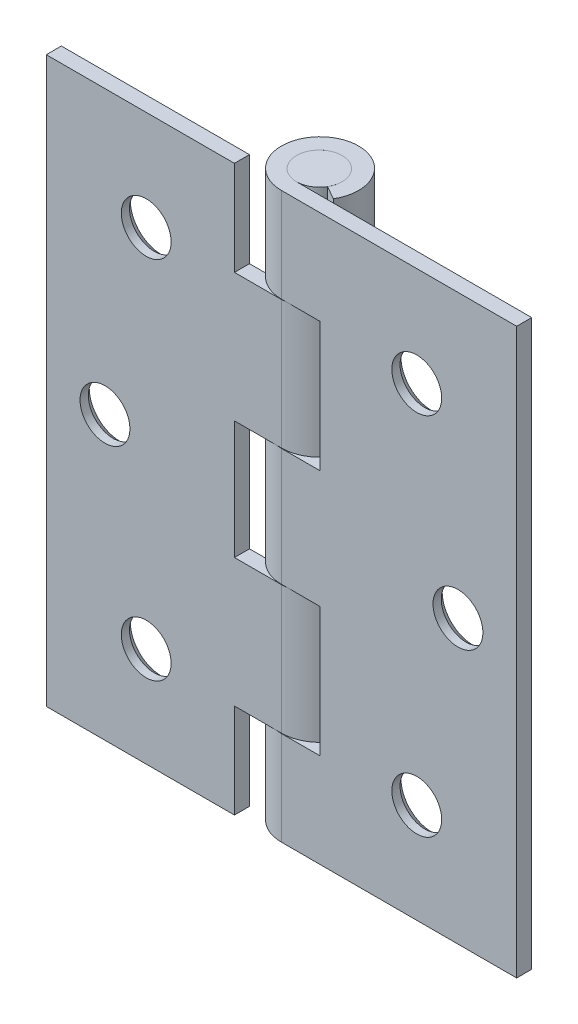
from build123d import *

# Parameters (mm, degrees)
EXTRUDE1_DEPTH                                = 38.1
CUT_EXTRUDE1_DEPTH                            = 9.382
CUT_EXTRUDE1_DEPTH_BACK                       = 3.032
EXTRUDE2_DEPTH                                = 8.68045
EXTRUDE2_DEPTH_BACK                           = 8.68045
EXTRUDE3_DEPTH                                = 8.68045
EXTRUDE3_DEPTH_BACK                           = 8.68045
EXTRUDE4_START                                = -21.43125
SKETCH5_W                                     = 25.4
SKETCH5_H                                     = 2.032
EXTRUDE4_DEPTH                                = 76.2
SKETCH6_W                                     = 3.0734
SKETCH6_H                                     = 76.2
CSK_FOR_8_FLAT_HEAD_MACHINE_SCREW2_AT_2_COUNT = 2
CSK_FOR_8_FLAT_HEAD_MACHINE_SCREW2_AT_2_PITCH = 25.258138545
CSK_FOR_8_FLAT_HEAD_MACHINE_SCREW2_AT_3_COUNT = 2
CSK_FOR_8_FLAT_HEAD_MACHINE_SCREW2_AT_3_PITCH = 25.258138545
CSK_FOR_8_FLAT_HEAD_MACHINE_SCREW2_AT_4_COUNT = 2
CSK_FOR_8_FLAT_HEAD_MACHINE_SCREW2_AT_4_PITCH = 48.768985563
CSK_FOR_8_FLAT_HEAD_MACHINE_SCREW2_AT_5_COUNT = 2
CSK_FOR_8_FLAT_HEAD_MACHINE_SCREW2_AT_5_PITCH = 47.6504
CSK_FOR_8_FLAT_HEAD_MACHINE_SCREW2_AT_6_COUNT = 2
CSK_FOR_8_FLAT_HEAD_MACHINE_SCREW2_AT_6_PITCH = 48.768985563


with BuildPart() as part:
    # Sketch1 → Extrude1 (new body, symmetric)
    with BuildSketch(Plane(origin=(0, 0, 0), x_dir=(1, 0, 0), z_dir=(0, 1, 0))):
        with BuildLine():
            Line((0, -3.0734), (31.75, -3.0734))
            Line((31.75, -3.0734), (31.75, -5.1054))
            Line((31.75, -5.1054), (0, -5.1054))
            ThreePointArc((0, -5.1054), (-2.565305705, 4.63283114), (4.464756325, -2.577728266))
            Line((4.464756325, -2.577728266), (2.661642476, -1.5367))
            ThreePointArc((2.661642476, -1.5367), (-1.5367, 2.661642476), (0, -3.0734))
        make_face()
    extrude(amount=EXTRUDE1_DEPTH, both=True)

    # Sketch2 → Cut-Extrude1 (cut, two sides)
    with BuildSketch(Plane(origin=(0, 0, 3.0734), x_dir=(-1, 0, 0), z_dir=(0, 0, -1))) as cut_extrude1_sk:
        Polygon((5.207, 217.478391172), (5.207, 38.1), (5.207, 25.4), (-5.207, 25.4), (-5.207, 7.9375), (5.207, 7.9375), (5.207, -7.9375), (-5.207, -7.9375), (-5.207, -25.4), (5.207, -25.4), (5.207, -38.1), (5.207, -217.478391172), (363.963782344, -217.478391172), (363.963782344, 217.478391172), align=None)
    extrude(amount=CUT_EXTRUDE1_DEPTH, mode=Mode.SUBTRACT)
    extrude(cut_extrude1_sk.sketch, amount=-CUT_EXTRUDE1_DEPTH_BACK, mode=Mode.SUBTRACT)


with BuildPart() as body_2:
    # Sketch3 → Extrude2 (new body, two sides)
    with BuildSketch(Plane(origin=(0, 16.66875, 0), x_dir=(-1, 0, 0), z_dir=(0, 1, 0))) as extrude2_sk:
        with BuildLine():
            Line((31.75, 5.1054), (31.75, 3.0734))
            Line((31.75, 3.0734), (0, 3.0734))
            ThreePointArc((0, 3.0734), (-1.5367, -2.661642476), (2.661642476, 1.5367))
            Line((2.661642476, 1.5367), (4.434312541, 2.627817757))
            ThreePointArc((4.434312541, 2.627817757), (-2.539760888, -4.64719827), (0, 5.1054))
            Line((0, 5.1054), (31.75, 5.1054))
        make_face()
    extrude(amount=EXTRUDE2_DEPTH)
    extrude(extrude2_sk.sketch, amount=-EXTRUDE2_DEPTH_BACK)



with BuildPart() as body_3:
    # Sketch4 → Extrude3 (new body, two sides)
    with BuildSketch(Plane(origin=(0, -16.66875, 0), x_dir=(-1, 0, 0), z_dir=(0, 1, 0))) as extrude3_sk:
        with BuildLine():
            Line((0, 3.0734), (31.75, 3.0734))
            Line((31.75, 3.0734), (31.75, 5.1054))
            Line((31.75, 5.1054), (0, 5.1054))
            ThreePointArc((0, 5.1054), (-2.539760888, -4.64719827), (4.434312541, 2.627817757))
            Line((4.434312541, 2.627817757), (2.661642476, 1.5367))
            ThreePointArc((2.661642476, 1.5367), (-1.5367, -2.661642476), (0, 3.0734))
        make_face()
    extrude(amount=EXTRUDE3_DEPTH)
    extrude(extrude3_sk.sketch, amount=-EXTRUDE3_DEPTH_BACK)


with BuildPart() as body_2_1:
    add(body_2.part)

    add(body_3.part)  # Extrude4 merges body 3
    # Sketch5 → Extrude4 (add)
    with BuildSketch(Plane(origin=(0, -16.66875, 0), x_dir=(-1, 0, 0), z_dir=(0, 1, 0)).offset(EXTRUDE4_START)):
        with Locations((19.05, 4.0894)):
            Rectangle(SKETCH5_W, SKETCH5_H)
    extrude(amount=EXTRUDE4_DEPTH)

    # Sketch9 → CSK for #8 Flat Head Machine Screw2 (revolve, cut)
    with BuildSketch(Plane(origin=(-23.8252, 0, 3.0734), x_dir=(0, 1, 0), z_dir=(1, 0, 0))):
        Polygon((0, 0), (0, 4.130193213), (3.3655, 2.1079968), (3.3655, 0.920409763), (4.1656, 0), align=None)
    csk_for_8_flat_head_machine_screw2 = revolve(axis=Axis((-23.8252, 0, -3.2766), (0, 0, 1)), mode=Mode.SUBTRACT)

    # CSK for #8 Flat Head Machine Screw2 at 2: CSK for #8 Flat Head Machine Screw2 ×2
    with Locations(*[Vector(0.220230006, 0.975447971, 0) * (i * CSK_FOR_8_FLAT_HEAD_MACHINE_SCREW2_AT_2_PITCH) for i in range(1, CSK_FOR_8_FLAT_HEAD_MACHINE_SCREW2_AT_2_COUNT)]):
        add(csk_for_8_flat_head_machine_screw2, mode=Mode.SUBTRACT)

    # CSK for #8 Flat Head Machine Screw2 at 3: CSK for #8 Flat Head Machine Screw2 ×2
    with Locations(*[Vector(0.220230006, -0.975447971, 0) * (i * CSK_FOR_8_FLAT_HEAD_MACHINE_SCREW2_AT_3_PITCH) for i in range(1, CSK_FOR_8_FLAT_HEAD_MACHINE_SCREW2_AT_3_COUNT)]):
        add(csk_for_8_flat_head_machine_screw2, mode=Mode.SUBTRACT)


with BuildPart() as body_3_2:
    # Sketch6 → Revolve1 (revolve)
    with BuildSketch(Plane.XY):
        with Locations((-1.5367, 0)):
            Rectangle(SKETCH6_W, SKETCH6_H)
    revolve(axis=Axis((0, 42.361566849, 0), (0, -1, 0)))


with BuildPart() as part_1:
    add(part.part)

    # CSK for #8 Flat Head Machine Screw2 at 4: CSK for #8 Flat Head Machine Screw2 ×2
    with Locations(*[Vector(0.863003393, -0.505198124, 0) * (i * CSK_FOR_8_FLAT_HEAD_MACHINE_SCREW2_AT_4_PITCH) for i in range(1, CSK_FOR_8_FLAT_HEAD_MACHINE_SCREW2_AT_4_COUNT)]):
        add(csk_for_8_flat_head_machine_screw2, mode=Mode.SUBTRACT)

    # CSK for #8 Flat Head Machine Screw2 at 5: CSK for #8 Flat Head Machine Screw2 ×2
    with Locations(*[(i * CSK_FOR_8_FLAT_HEAD_MACHINE_SCREW2_AT_5_PITCH, 0, 0) for i in range(1, CSK_FOR_8_FLAT_HEAD_MACHINE_SCREW2_AT_5_COUNT)]):
        add(csk_for_8_flat_head_machine_screw2, mode=Mode.SUBTRACT)

    # CSK for #8 Flat Head Machine Screw2 at 6: CSK for #8 Flat Head Machine Screw2 ×2
    with Locations(*[Vector(0.863003393, 0.505198124, 0) * (i * CSK_FOR_8_FLAT_HEAD_MACHINE_SCREW2_AT_6_PITCH) for i in range(1, CSK_FOR_8_FLAT_HEAD_MACHINE_SCREW2_AT_6_COUNT)]):
        add(csk_for_8_flat_head_machine_screw2, mode=Mode.SUBTRACT)


solid = Compound([body_2_1.part, body_3_2.part, part_1.part])
